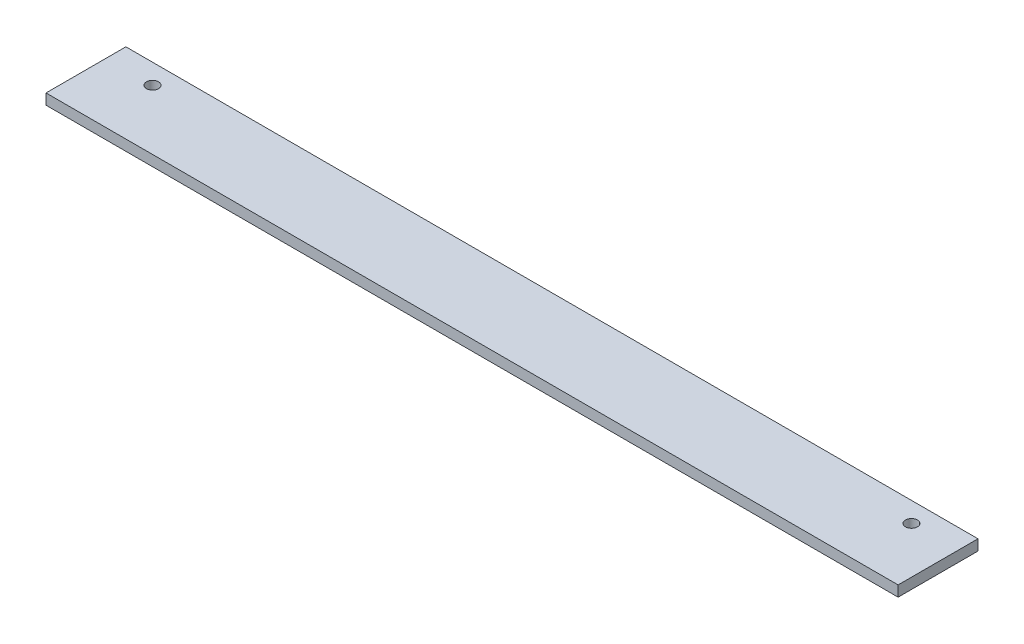
from build123d import *

# Parameters (mm, degrees)
SKETCH_1_W          = 30
SKETCH_1_H          = 4
EXTRUDE_1_DEPTH     = 320
SKETCH_2_R          = 2.25
CUT_EXTRUDE_1_DEPTH = 5


with BuildPart() as part:
    # Эскиз1 → Бобышка-Вытянуть1 (new body)
    with BuildSketch(Plane(origin=(0, 0, 0), x_dir=(0, 0, -1), z_dir=(1, 0, 0))):
        Rectangle(SKETCH_1_W, SKETCH_1_H)
    extrude(amount=EXTRUDE_1_DEPTH)

    # Эскиз2 → Вырез-Вытянуть1 (cut, through all)
    with BuildSketch(Plane(origin=(0, 2, 0), x_dir=(1, 0, 0), z_dir=(0, 1, 0))):
        with Locations((17.5, 7.5)):
            Circle(SKETCH_2_R)
        with Locations((302.5, 7.5)):
            Circle(SKETCH_2_R)
    extrude(amount=-CUT_EXTRUDE_1_DEPTH, mode=Mode.SUBTRACT)


solid = part.part
